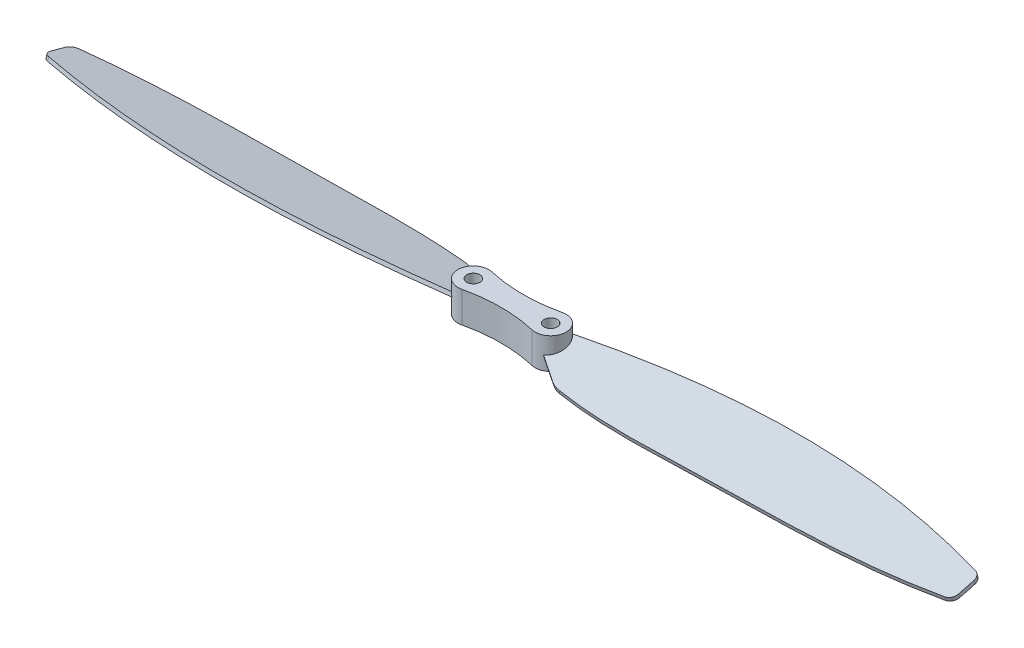
from build123d import *

# Parameters (mm, degrees)
EXTRUDE_1_DEPTH          = 4
EXTRUDE_2_DEPTH          = 0.25
PATTERN_CIRCULAR_1_COUNT = 2
SKETCH_4_R               = 0.85
CUT_EXTRUDE_1_DEPTH      = 5.0000001


with BuildPart() as part:
    # 草图1 → 凸台-拉伸1 (new body)
    with BuildSketch(Plane(origin=(0, 0, 0), x_dir=(1, 0, 0), z_dir=(0, 1, 0))):
        with BuildLine():
            ThreePointArc((4.545454545, 1.947662299), (0, 1.424285286), (-4.545454545, 1.947662299))
            ThreePointArc((-4.545454545, 1.947662299), (-7, 0), (-4.545454545, -1.947662299))
            ThreePointArc((-4.545454545, -1.947662299), (0, -1.424285286), (4.545454545, -1.947662299))
            ThreePointArc((4.545454545, -1.947662299), (7, 0), (4.545454545, 1.947662299))
        make_face()
    extrude(amount=EXTRUDE_1_DEPTH)

    # 草图3 → 凸台-拉伸2 (add, symmetric)
    with BuildSketch(Plane(origin=(0, 1.866025404, 0.5), x_dir=(0, 0.258819045, -0.965925826), z_dir=(0, -0.965925826, -0.258819045))):
        with BuildLine():
            Line((-0.721025856, 5), (-3.244156646, 8.963824719))
            ThreePointArc((-3.244156646, 8.963824719), (-3.530742288, 9.544023278), (-3.686238371, 10.172181433))
            add(Edge.make_bspline(
                [(-3.686238371, 10.172181433), (-4.525441011, 16.369200543), (-3.695143097, 32.261586596), (-4.002824546, 48.145456087), (-2.214031519, 58.654900349)],
                knots=[0.01661138, 0.01661138, 0.01661138, 0.01661138, 0.374640407, 0.984355774, 0.984355774, 0.984355774, 0.984355774], degree=3))
            ThreePointArc((-2.214031519, 58.654900349), (-1.881256083, 59.24442325), (-1.249204631, 59.486885007))
            ThreePointArc((-1.249204631, 59.486885007), (-0.196436424, 59.499675736), (0.85639329, 59.493836576))
            ThreePointArc((0.85639329, 59.493836576), (1.46199409, 59.278546742), (1.811474117, 58.739134328))
            add(Edge.make_bspline(
                [(1.931851653, 5), (5.579965015, 23.055167147), (6.356652938, 40.76793724), (1.811474117, 58.739134328)],
                knots=[0, 0, 0, 0, 0.986483201, 0.986483201, 0.986483201, 0.986483201], degree=3))
            Line((1.931851653, 5), (-0.721025856, 5))
        make_face()
    extrude_2 = extrude(amount=EXTRUDE_2_DEPTH, both=True)

    # 阵列(圆周)1: 凸台-拉伸2 ×2 about axis
    pattern_circular_1_axis = Axis((0, 4.2, 0), (0, -1, 0))
    for i in range(1, PATTERN_CIRCULAR_1_COUNT):
        add(extrude_2.rotate(pattern_circular_1_axis, i * 360 / PATTERN_CIRCULAR_1_COUNT))

    # 草图4 → 切除-拉伸1 (cut, through all)
    with BuildSketch(Plane(origin=(0, 4, 0), x_dir=(1, 0, 0), z_dir=(0, 1, 0))):
        with Locations((-5, 0)):
            Circle(SKETCH_4_R)
        with Locations((5, 0)):
            Circle(SKETCH_4_R)
    extrude(amount=-CUT_EXTRUDE_1_DEPTH, mode=Mode.SUBTRACT)


solid = part.part
